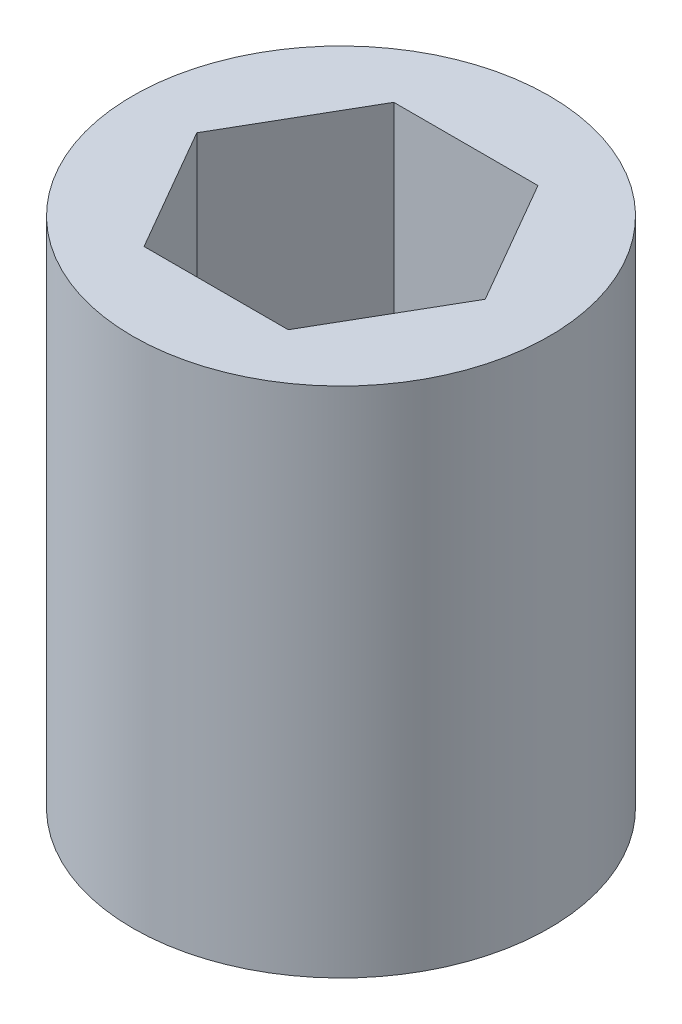
from build123d import *

# Parameters (mm, degrees)
SKETCH1_R           = 1.625
BOSS_EXTRUDE1_DEPTH = 4
CUT_EXTRUDE1_DEPTH  = 3.5


with BuildPart() as part:
    # Sketch1 → Boss-Extrude1 (new body)
    with BuildSketch(Plane(origin=(0, 0, 0), x_dir=(1, 0, 0), z_dir=(0, 1, 0))):
        Circle(SKETCH1_R)
    extrude(amount=BOSS_EXTRUDE1_DEPTH)

    # Sketch2 → Cut-Extrude1 (cut)
    with BuildSketch(Plane(origin=(0, 4, 0), x_dir=(1, 0, 0), z_dir=(0, 1, 0))):
        Polygon((1.125, 0), (0.5625, 0.974278579), (-0.5625, 0.974278579), (-1.125, 0), (-0.5625, -0.974278579), (0.5625, -0.974278579), align=None)
    extrude(amount=-CUT_EXTRUDE1_DEPTH, mode=Mode.SUBTRACT)


solid = part.part
